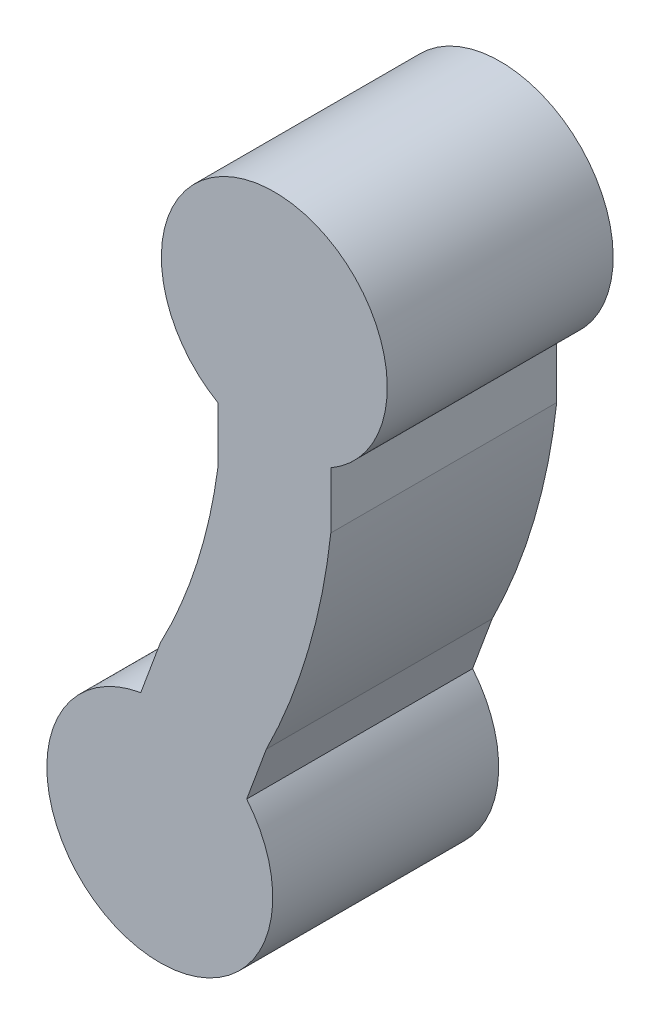
from build123d import *

# Parameters (mm, degrees)
EXTRUDE_1_DEPTH = 2


with BuildPart() as part:
    # 草图1 → 凸台-拉伸1 (new body)
    with BuildSketch(Plane.XY):
        with BuildLine():
            Line((0.5, -1.366025404), (0.5, -0.866025404))
            ThreePointArc((0.5, -0.866025404), (0, 1), (-0.5, -0.866025404))
            Line((-0.5, -0.866025404), (-0.5, -1.366025404))
            ThreePointArc((-0.5, -1.366025404), (-0.683604615, -2.186753802), (-1.008959149, -2.962285996))
            Line((-1.008959149, -2.962285996), (-1.182414706, -3.431235001))
            ThreePointArc((-1.182414706, -3.431235001), (-1.360810655, -5.354832073), (-0.244516696, -3.778146116))
            Line((-0.244516696, -3.778146116), (-0.071061138, -3.309197111))
            ThreePointArc((-0.071061138, -3.309197111), (0.300747459, -2.362966726), (0.5, -1.366025404))
        make_face()
    extrude(amount=-EXTRUDE_1_DEPTH)


solid = part.part
